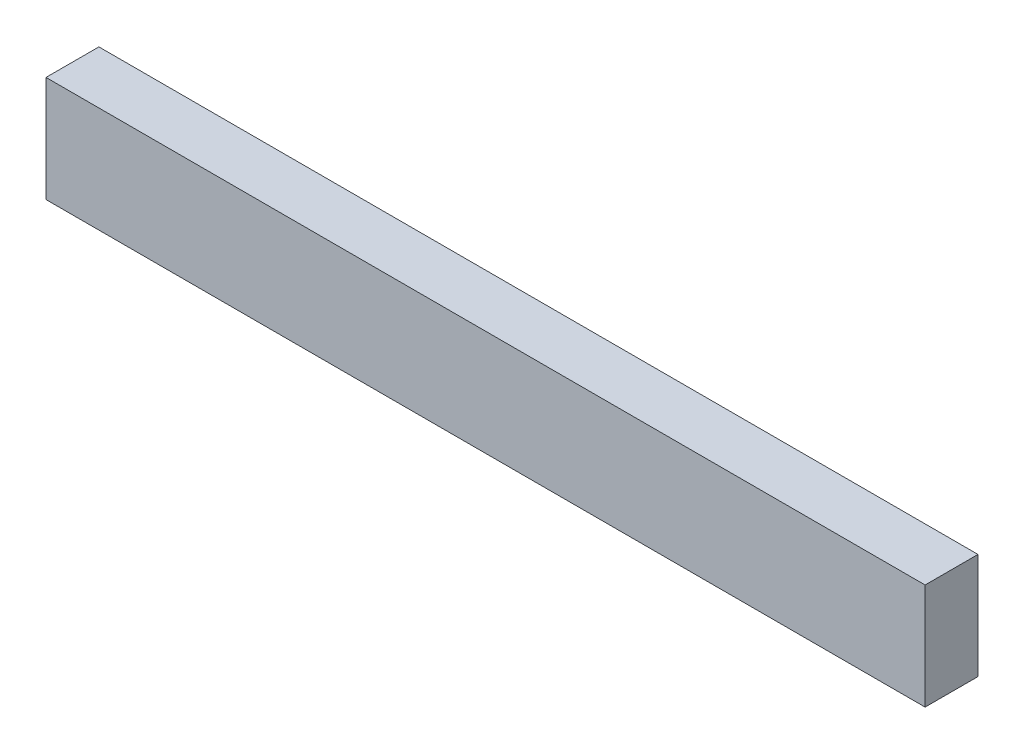
from build123d import *

# Parameters (mm, degrees)
SKETCH1_W           = 316.5856
SKETCH1_H           = 38.1
BOSS_EXTRUDE1_DEPTH = 19.05


with BuildPart() as part:
    # Sketch1 → Boss-Extrude1 (new body)
    with BuildSketch(Plane.XY):
        with Locations((122.213833245, 10.525848514)):
            Rectangle(SKETCH1_W, SKETCH1_H)
    extrude(amount=BOSS_EXTRUDE1_DEPTH)


solid = part.part
